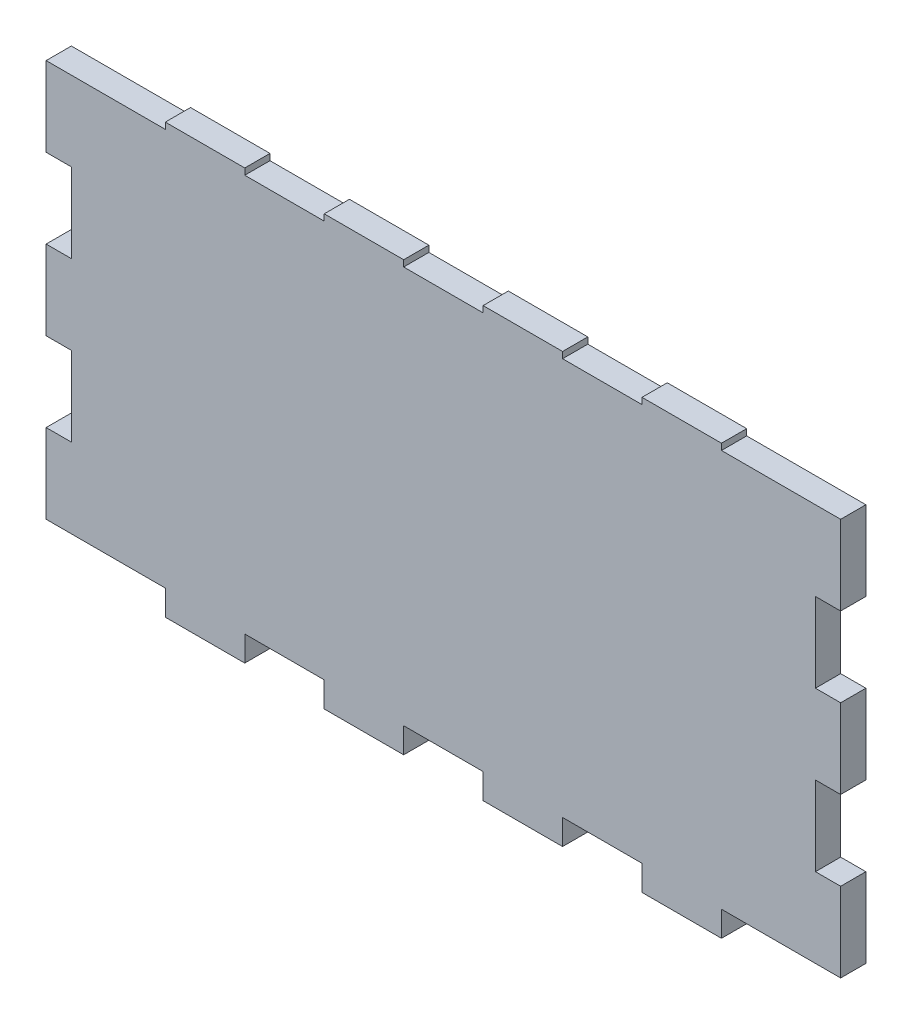
from build123d import *

# Parameters (mm, degrees)
SKETCH1_W           = 20
SKETCH1_H           = 6.35
SKETCH1_H_2         = 1.5875
BOSS_EXTRUDE1_DEPTH = 6.35


with BuildPart() as part:
    # Sketch1 → Boss-Extrude1 (new body)
    with BuildSketch(Plane.XY):
        Polygon((0, 20), (0, 0), (30, 0), (50, 0), (70, 0), (90, 0), (110, 0), (130, 0), (150, 0), (170, 0), (200, 0), (200, 20), (193.65, 20), (193.65, 40), (200, 40), (200, 60), (193.65, 60), (193.65, 80), (200, 80), (200, 100), (170, 100), (150, 100), (130, 100), (110, 100), (90, 100), (70, 100), (50, 100), (30, 100), (0, 100), (0, 80), (6.35, 80), (6.35, 60), (0, 60), (0, 40), (6.35, 40), (6.35, 20), align=None)
        with Locations((40, -3.175)):
            Rectangle(SKETCH1_W, SKETCH1_H)
        with Locations((80, -3.175)):
            Rectangle(SKETCH1_W, SKETCH1_H)
        with Locations((120, -3.175)):
            Rectangle(SKETCH1_W, SKETCH1_H)
        with Locations((160, -3.175)):
            Rectangle(SKETCH1_W, SKETCH1_H)
        with Locations((40, 100.79375)):
            Rectangle(SKETCH1_W, SKETCH1_H_2)
        with Locations((80, 100.79375)):
            Rectangle(SKETCH1_W, SKETCH1_H_2)
        with Locations((120, 100.79375)):
            Rectangle(SKETCH1_W, SKETCH1_H_2)
        with Locations((160, 100.79375)):
            Rectangle(SKETCH1_W, SKETCH1_H_2)
    extrude(amount=BOSS_EXTRUDE1_DEPTH)


solid = part.part
